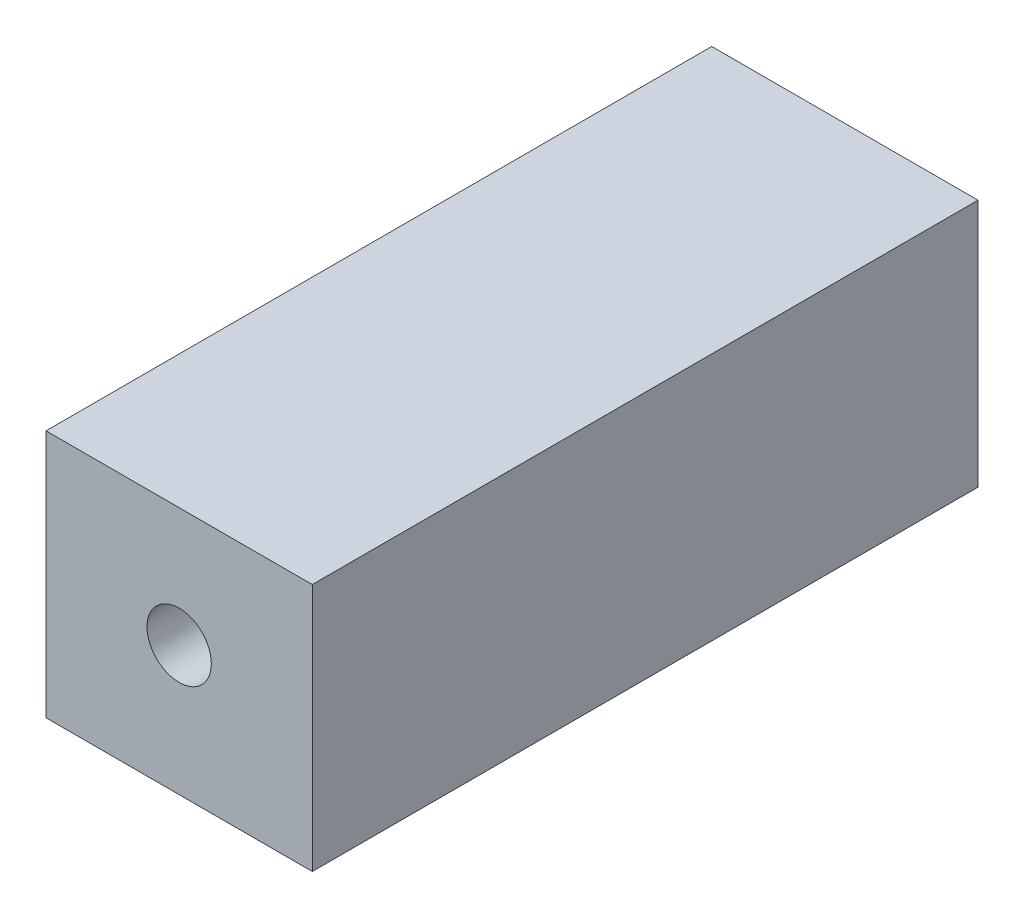
from build123d import *

# Parameters (mm, degrees)
SKETCH1_W           = 12
SKETCH1_H           = 11.2
SKETCH1_R           = 1.45
BOSS_EXTRUDE1_DEPTH = 30


with BuildPart() as part:
    # Sketch1 → Boss-Extrude1 (new body)
    with BuildSketch(Plane.XY):
        with Locations((0, -0.23)):
            Rectangle(SKETCH1_W, SKETCH1_H)
        Circle(SKETCH1_R, mode=Mode.SUBTRACT)
    extrude(amount=BOSS_EXTRUDE1_DEPTH)


solid = part.part
